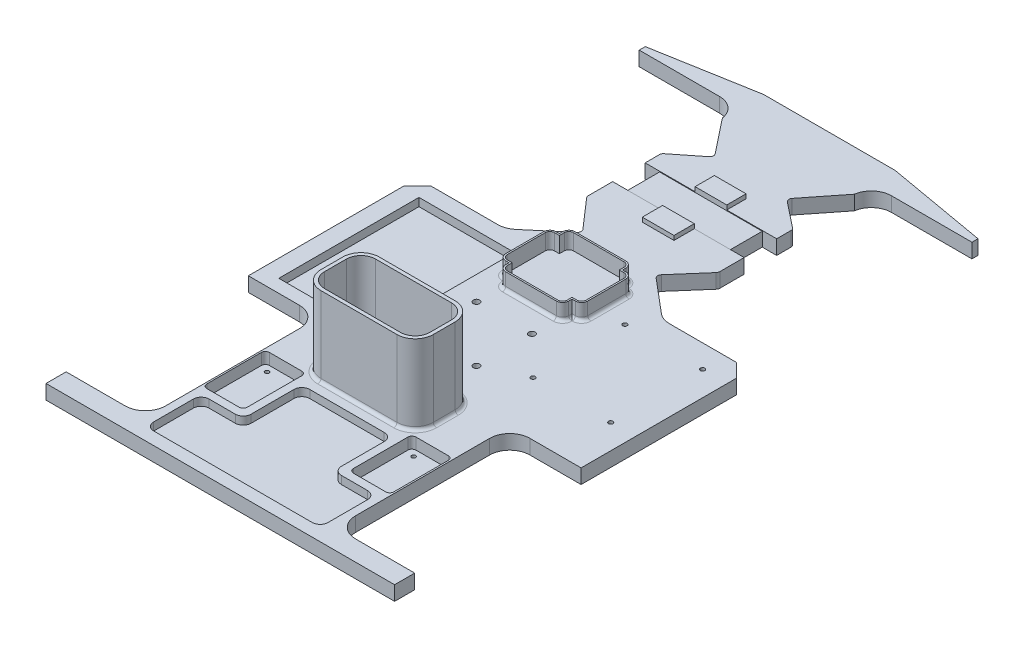
from build123d import *

# Parameters (mm, degrees)
BOSS_EXTRUDE1_DEPTH = 7.62
CUT_EXTRUDE1_DEPTH  = 401.20242682
FILLET2_R           = 12.7
FILLET3_R           = 12.7
BOSS_EXTRUDE2_DEPTH = 50
FILLET4_R           = 2
CUT_EXTRUDE3_START  = -5.08
CUT_EXTRUDE3_DEPTH  = 5.08
CUT_EXTRUDE4_DEPTH  = 7.15
SKETCH13_W          = 83
SKETCH13_H          = 20.5
CUT_EXTRUDE5_DEPTH  = 0.43499
SKETCH14_W          = 20.5
SKETCH14_H          = 7.18501
CUT_EXTRUDE6_DEPTH  = 9.1
SKETCH15_W          = 20.5
SKETCH15_H          = 7.18501
CUT_EXTRUDE7_DEPTH  = 9.1
SKETCH11_W          = 60.25
SKETCH11_H          = 88.46
CUT_EXTRUDE8_DEPTH  = 5.08
BOSS_EXTRUDE3_DEPTH = 1.5
SKETCH17_W          = 20
SKETCH17_H          = 12.188741635
SKETCH17_H_2        = 12.811258365
BOSS_EXTRUDE4_DEPTH = 2.74001
SKETCH18_R          = 2
SKETCH18_R_2        = 1.375
SKETCH18_R_3        = 1.27
SKETCH18_R_4        = 1
CUT_EXTRUDE9_DEPTH  = 404.241761271
CUT_EXTRUDE10_DEPTH = 404.241761271
CUT_EXTRUDE11_DEPTH = 5
FILLET5_R           = 2.5
BOSS_EXTRUDE5_DEPTH = 10
FILLET6_R           = 2


with BuildPart() as part:
    # Sketch4 → Boss-Extrude1 (new body)
    with BuildSketch(Plane(origin=(0, 0, 0), x_dir=(1, 0, 0), z_dir=(0, 1, 0))):
        Polygon((56.7, 201.69), (56.7, 186.69), (-6.8, 186.69), (-6.8, 80.01), (38.2, 80.01), (38.2, -29.99), (-11.8, -29.99), (-11.8, -42.69), (208.2, -42.69), (208.2, -29.99), (158.2, -29.99), (158.2, 80.01), (203.2, 80.01), (203.2, 186.69), (139.7, 186.69), (139.7, 201.69), (139.7, 236.69), (139.7, 276.69), (139.7, 326.69), (203.2, 326.69), (203.2, 330.5), (139.7, 341.696763275), (56.7, 341.696763275), (-6.8, 330.5), (-6.8, 326.69), (56.7, 326.69), (56.7, 311.69), (56.7, 236.69), align=None)
    extrude(amount=BOSS_EXTRUDE1_DEPTH)

    # Sketch5 → Cut-Extrude1 (cut, through all)
    with BuildSketch(Plane(origin=(0, 7.62, 0), x_dir=(1, 0, 0), z_dir=(0, 1, 0))):
        Polygon((-6.8, 186.69), (-6.8, 178.204718626), (1.685281374, 186.69), align=None)
        Polygon((194.714718626, 186.69), (203.2, 178.204718626), (203.2, 186.69), align=None)
    extrude(amount=-CUT_EXTRUDE1_DEPTH, mode=Mode.SUBTRACT)

    # Fillet2
    fillet2_edges = [part.edges().sort_by_distance(p)[0] for p in [
        (139.7, 3.81, -186.69),
        (139.7, 3.81, -326.69),
        (56.7, 3.81, -186.69),
        (56.7, 3.81, -326.69),
    ]]
    fillet(fillet2_edges, radius=FILLET2_R)

    # Fillet3
    fillet3_edges = [part.edges().sort_by_distance(p)[0] for p in [
        (158.2, 3.81, 29.99),
        (158.2, 3.81, -80.01),
        (38.2, 3.81, 29.99),
        (38.2, 3.81, -80.01),
    ]]
    fillet(fillet3_edges, radius=FILLET3_R)

    # Sketch6 → Boss-Extrude2 (add)
    with BuildSketch(Plane(origin=(0, 7.62, 0), x_dir=(1, 0, 0), z_dir=(0, 1, 0))):
        with BuildLine():
            Line((74.235100031, 81.57233804), (122.164900031, 81.572337374))
            ThreePointArc((122.164900031, 81.572337374), (130.296168152, 78.204255822), (133.664249871, 70.072987771))
            Line((133.664249871, 70.072987771), (133.664250347, 56.306187771))
            ThreePointArc((133.664250347, 56.306187771), (130.296168795, 48.174919093), (122.164900187, 44.806837374))
            Line((122.164900187, 44.806837374), (74.235100187, 44.80683804))
            ThreePointArc((74.235100187, 44.80683804), (66.103832067, 48.174919592), (62.735750347, 56.306187643))
            Line((62.735750347, 56.306187643), (62.735749871, 70.072987643))
            ThreePointArc((62.735749871, 70.072987643), (66.103831423, 78.20425632), (74.235100031, 81.57233804))
        make_face()
        with BuildLine():
            Line((64.985750347, 56.306187721), (64.985749871, 70.072987721))
            ThreePointArc((64.985749871, 70.072987721), (67.694821697, 76.613266079), (74.2351, 79.32233804))
            Line((74.2351, 79.32233804), (122.1649, 79.322337374))
            ThreePointArc((122.1649, 79.322337374), (128.70517791, 76.613265548), (131.414249871, 70.072987693))
            Line((131.414249871, 70.072987693), (131.414250347, 56.306187693))
            ThreePointArc((131.414250347, 56.306187693), (128.705178521, 49.765909334), (122.164900218, 47.056837374))
            Line((122.164900218, 47.056837374), (74.235100218, 47.05683804))
            ThreePointArc((74.235100218, 47.05683804), (67.694822308, 49.765909866), (64.985750347, 56.306187721))
        make_face(mode=Mode.SUBTRACT)
    extrude(amount=BOSS_EXTRUDE2_DEPTH)

    # Fillet4
    fillet4_edges = [part.edges().sort_by_distance(p)[0] for p in [
        (66.103832067, 7.62, -48.174919592),
        (98.200000187, 7.62, -44.806837707),
        (130.296168795, 7.62, -48.174919093),
        (133.664250109, 7.62, -63.189587771),
        (130.296168152, 7.62, -78.204255822),
        (98.200000031, 7.62, -81.572337707),
        (66.103831423, 7.62, -78.20425632),
        (62.735750109, 7.62, -63.189587643),
    ]]
    fillet(fillet4_edges, radius=FILLET4_R)

    # Sketch6_5 → Cut-Extrude3 (cut)
    with BuildSketch(Plane(origin=(0, 7.62, 0), x_dir=(1, 0, 0), z_dir=(0, 1, 0)).offset(CUT_EXTRUDE3_START)):
        with BuildLine():
            Line((64.985749871, 70.072987721), (64.985750347, 56.306187721))
            ThreePointArc((64.985750347, 56.306187721), (67.694822308, 49.765909866), (74.235100218, 47.05683804))
            Line((74.235100218, 47.05683804), (122.164900218, 47.056837374))
            ThreePointArc((122.164900218, 47.056837374), (128.705178521, 49.765909334), (131.414250347, 56.306187693))
            Line((131.414250347, 56.306187693), (131.414249871, 70.072987693))
            ThreePointArc((131.414249871, 70.072987693), (128.70517791, 76.613265548), (122.1649, 79.322337374))
            Line((122.1649, 79.322337374), (74.2351, 79.32233804))
            ThreePointArc((74.2351, 79.32233804), (67.694821697, 76.613266079), (64.985749871, 70.072987721))
        make_face()
    extrude(amount=CUT_EXTRUDE3_DEPTH, mode=Mode.SUBTRACT)

    # Sketch8 → Cut-Extrude4 (cut)
    with BuildSketch(Plane(origin=(0, 7.62, 0), x_dir=(1, 0, 0), z_dir=(0, 1, 0))):
        with BuildLine():
            ThreePointArc((41.74, 44.76), (39.943948776, 44.016051224), (39.2, 42.22))
            Line((39.2, 42.22), (39.2, 7.8))
            ThreePointArc((39.2, 7.8), (39.943948776, 6.003948776), (41.74, 5.26))
            Line((41.74, 5.26), (62.16, 5.26))
            ThreePointArc((62.16, 5.26), (63.956051224, 6.003948776), (64.7, 7.8))
            Line((64.7, 7.8), (64.7, 42.22))
            ThreePointArc((64.7, 42.22), (63.956051224, 44.016051224), (62.16, 44.76))
            Line((62.16, 44.76), (41.74, 44.76))
        make_face()
        with BuildLine():
            Line((154.66, 44.76), (134.24, 44.76))
            ThreePointArc((134.24, 44.76), (132.443948776, 44.016051224), (131.7, 42.22))
            Line((131.7, 42.22), (131.7, 7.8))
            ThreePointArc((131.7, 7.8), (132.443948776, 6.003948776), (134.24, 5.26))
            Line((134.24, 5.26), (154.66, 5.26))
            ThreePointArc((154.66, 5.26), (156.456051224, 6.003948776), (157.2, 7.8))
            Line((157.2, 7.8), (157.2, 42.22))
            ThreePointArc((157.2, 42.22), (156.456051224, 44.016051224), (154.66, 44.76))
        make_face()
    extrude(amount=-CUT_EXTRUDE4_DEPTH, mode=Mode.SUBTRACT)

    # Sketch13 → Cut-Extrude5 (cut)
    with BuildSketch(Plane(origin=(0, 7.62, 0), x_dir=(1, 0, 0), z_dir=(0, 1, 0))):
        with Locations((98.2, 256.69)):
            Rectangle(SKETCH13_W, SKETCH13_H)
    extrude(amount=-CUT_EXTRUDE5_DEPTH, mode=Mode.SUBTRACT)

    # Sketch14 → Cut-Extrude6 (cut)
    with BuildSketch(Plane.ZY.offset(-56.7)):
        with Locations((-256.69, 3.592505)):
            Rectangle(SKETCH14_W, SKETCH14_H)
    extrude(amount=-CUT_EXTRUDE6_DEPTH, mode=Mode.SUBTRACT)

    # Sketch15 → Cut-Extrude7 (cut)
    with BuildSketch(Plane(origin=(139.7, 0, 0), x_dir=(0, 0, -1), z_dir=(1, 0, 0))):
        with Locations((256.69, 3.592505)):
            Rectangle(SKETCH15_W, SKETCH15_H)
    extrude(amount=-CUT_EXTRUDE7_DEPTH, mode=Mode.SUBTRACT)

    # Sketch11 → Cut-Extrude8 (cut)
    with BuildSketch(Plane(origin=(0, 7.62, 0), x_dir=(1, 0, 0), z_dir=(0, 1, 0))):
        with Locations((34.325, 132.46)):
            Rectangle(SKETCH11_W, SKETCH11_H)
    extrude(amount=-CUT_EXTRUDE8_DEPTH, mode=Mode.SUBTRACT)

    # Sketch16 → Boss-Extrude3 (add)
    with BuildSketch(Plane.XZ):
        with BuildLine():
            Line((130.6, -246.44), (139.7, -246.44))
            Line((139.7, -246.44), (139.7, -199.39))
            ThreePointArc((139.7, -199.39), (143.419743879, -190.409743879), (152.4, -186.69))
            Line((152.4, -186.69), (194.714718626, -186.69))
            Line((194.714718626, -186.69), (203.2, -178.204718626))
            Line((203.2, -178.204718626), (203.2, -80.01))
            Line((203.2, -80.01), (170.9, -80.01))
            ThreePointArc((170.9, -80.01), (161.919743879, -76.290256121), (158.2, -67.31))
            Line((158.2, -67.31), (158.2, 17.29))
            ThreePointArc((158.2, 17.29), (161.919743879, 26.270256121), (170.9, 29.99))
            Line((170.9, 29.99), (208.2, 29.99))
            Line((208.2, 29.99), (208.2, 42.69))
            Line((208.2, 42.69), (-11.8, 42.69))
            Line((-11.8, 42.69), (-11.8, 29.99))
            Line((-11.8, 29.99), (25.5, 29.99))
            ThreePointArc((25.5, 29.99), (34.480256121, 26.270256121), (38.2, 17.29))
            Line((38.2, 17.29), (38.2, -67.31))
            ThreePointArc((38.2, -67.31), (34.480256121, -76.290256121), (25.5, -80.01))
            Line((25.5, -80.01), (-6.8, -80.01))
            Line((-6.8, -80.01), (-6.8, -178.204718626))
            Line((-6.8, -178.204718626), (1.685281374, -186.69))
            Line((1.685281374, -186.69), (44, -186.69))
            ThreePointArc((44, -186.69), (52.980256121, -190.409743879), (56.7, -199.39))
            Line((56.7, -199.39), (56.7, -246.44))
            Line((56.7, -246.44), (65.8, -246.44))
            Line((65.8, -246.44), (65.8, -266.94))
            Line((65.8, -266.94), (56.7, -266.94))
            Line((56.7, -266.94), (56.7, -313.99))
            ThreePointArc((56.7, -313.99), (52.980256121, -322.970256121), (44, -326.69))
            Line((44, -326.69), (-6.8, -326.69))
            Line((-6.8, -326.69), (-6.8, -330.5))
            Line((-6.8, -330.5), (56.7, -341.696763275))
            Line((56.7, -341.696763275), (139.7, -341.696763275))
            Line((139.7, -341.696763275), (203.2, -330.5))
            Line((203.2, -330.5), (203.2, -326.69))
            Line((203.2, -326.69), (152.4, -326.69))
            ThreePointArc((152.4, -326.69), (143.419743879, -322.970256121), (139.7, -313.99))
            Line((139.7, -313.99), (139.7, -266.94))
            Line((139.7, -266.94), (130.6, -266.94))
            Line((130.6, -266.94), (130.6, -246.44))
        make_face()
    extrude(amount=BOSS_EXTRUDE3_DEPTH)

    # Sketch17 → Boss-Extrude4 (add)
    with BuildSketch(Plane(origin=(0, 7.62, 0), x_dir=(1, 0, 0), z_dir=(0, 1, 0))):
        with Locations((98.2, 273.034370818)):
            Rectangle(SKETCH17_W, SKETCH17_H)
        with Locations((98.2, 240.034370818)):
            Rectangle(SKETCH17_W, SKETCH17_H_2)
    extrude(amount=BOSS_EXTRUDE4_DEPTH)

    # Sketch18 → Cut-Extrude9 (cut, through all)
    with BuildSketch(Plane(origin=(0, 7.62, 0), x_dir=(1, 0, 0), z_dir=(0, 1, 0))):
        with Locations((79.421390026, 137.748707855)):
            Circle(SKETCH18_R)
        with Locations((79.421390026, 102.748707855)):
            Circle(SKETCH18_R)
        with Locations((114.421390026, 137.748707855)):
            Circle(SKETCH18_R)
        with Locations((114.421390026, 102.748707855)):
            Circle(SKETCH18_R)
        with Locations((138.7, 114.19)):
            Circle(SKETCH18_R_2)
        with Locations((187.7, 114.19)):
            Circle(SKETCH18_R_2)
        with Locations((187.7, 172.19)):
            Circle(SKETCH18_R_2)
        with Locations((138.7, 172.19)):
            Circle(SKETCH18_R_2)
        with Locations((59.36397425, 40.497408)):
            Circle(SKETCH18_R_3)
        with Locations((44.52397425, 40.497408)):
            Circle(SKETCH18_R_3)
        with Locations((44.52397425, 9.527408)):
            Circle(SKETCH18_R_3)
        with Locations((59.36397425, 9.527408)):
            Circle(SKETCH18_R_3)
        with Locations((137.02397425, 9.527408)):
            Circle(SKETCH18_R_3)
        with Locations((151.86397425, 9.527408)):
            Circle(SKETCH18_R_3)
        with Locations((151.86397425, 40.497408)):
            Circle(SKETCH18_R_3)
        with Locations((137.02397425, 40.497408)):
            Circle(SKETCH18_R_3)
        with Locations((98.45818237, 238.878741635)):
            Circle(SKETCH18_R_4)
        with Locations((98.45818237, 273.878741635)):
            Circle(SKETCH18_R_4)
    extrude(amount=-CUT_EXTRUDE9_DEPTH, mode=Mode.SUBTRACT)

    # Sketch20 → Cut-Extrude10 (cut, through all)
    with BuildSketch(Plane(origin=(0, 7.62, 0), x_dir=(1, 0, 0), z_dir=(0, 1, 0))):
        with BuildLine():
            Line((121.29420234, 208.981872288), (139.7, 230.108326069))
            Line((139.7, 230.108326069), (139.7, 199.39))
            ThreePointArc((139.7, 199.39), (140.88511792, 194.032996109), (144.219289872, 189.675784551))
            Line((144.219289872, 189.675784551), (121.29420234, 208.981872288))
        make_face()
        Polygon((139.833467491, 315.826371611), (139.7, 313.99), (139.7, 277.167730227), (120.971300539, 291.984980177), align=None)
        Polygon((56.7, 277.167730227), (75.428699461, 291.984980177), (56.566532509, 315.826371611), (56.7, 313.99), align=None)
        with BuildLine():
            Line((75.10579766, 208.981872288), (56.7, 230.108326069))
            Line((56.7, 230.108326069), (56.7, 199.39))
            ThreePointArc((56.7, 199.39), (55.51488208, 194.032996109), (52.180710128, 189.675784551))
            Line((52.180710128, 189.675784551), (75.10579766, 208.981872288))
        make_face()
    extrude(amount=-CUT_EXTRUDE10_DEPTH, mode=Mode.SUBTRACT)

    # Sketch21 → Cut-Extrude11 (cut)
    with BuildSketch(Plane(origin=(0, 7.62, 0), x_dir=(1, 0, 0), z_dir=(0, 1, 0))):
        with BuildLine():
            Line((74.7, 37.26763454), (121.7, 37.26763454))
            ThreePointArc((121.7, 37.26763454), (125.235533906, 35.803168446), (126.7, 32.26763454))
            Line((126.7, 32.26763454), (126.7, 5.26))
            ThreePointArc((126.7, 5.26), (128.164466094, 1.724466094), (131.7, 0.26))
            Line((131.7, 0.26), (148.2, 0.26))
            ThreePointArc((148.2, 0.26), (151.735533906, -1.204466094), (153.2, -4.74))
            Line((153.2, -4.74), (153.2, -29.69))
            ThreePointArc((153.2, -29.69), (151.735533906, -33.225533906), (148.2, -34.69))
            Line((148.2, -34.69), (126.7, -34.69))
            Line((126.7, -34.69), (69.7, -34.69))
            Line((69.7, -34.69), (48.2, -34.69))
            ThreePointArc((48.2, -34.69), (44.664466094, -33.225533906), (43.2, -29.69))
            Line((43.2, -29.69), (43.2, -4.74))
            ThreePointArc((43.2, -4.74), (44.664466094, -1.204466094), (48.2, 0.26))
            Line((48.2, 0.26), (64.7, 0.26))
            ThreePointArc((64.7, 0.26), (68.235533906, 1.724466094), (69.7, 5.26))
            Line((69.7, 5.26), (69.7, 32.26763454))
            ThreePointArc((69.7, 32.26763454), (71.164466094, 35.803168446), (74.7, 37.26763454))
        make_face()
    extrude(amount=-CUT_EXTRUDE11_DEPTH, mode=Mode.SUBTRACT)

    # Fillet5
    fillet5_edges = [part.edges().sort_by_distance(p)[0] for p in [
        (139.7, 3.06, -230.108326069),
        (139.7, 3.06, -277.167730227),
        (120.971300539, 3.06, -291.984980177),
        (56.7, 3.06, -277.167730227),
        (75.428699461, 3.06, -291.984980177),
        (121.29420234, 3.06, -208.981872288),
        (56.7, 3.06, -230.108326069),
        (75.10579766, 3.06, -208.981872288),
    ]]
    fillet(fillet5_edges, radius=FILLET5_R)

    # Sketch22 → Boss-Extrude5 (add)
    with BuildSketch(Plane(origin=(0, 7.62, 0), x_dir=(1, 0, 0), z_dir=(0, 1, 0))):
        with BuildLine():
            Line((78.3, 159.403016825), (76.2, 159.403016825))
            ThreePointArc((76.2, 159.403016825), (73.442283553, 160.545300378), (72.3, 163.303016825))
            Line((72.3, 163.303016825), (72.3, 187.303016825))
            ThreePointArc((72.3, 187.303016825), (73.442283553, 190.060733272), (76.2, 191.203016825))
            Line((76.2, 191.203016825), (78.3, 191.203016825))
            Line((78.3, 191.203016825), (78.3, 193.303016825))
            ThreePointArc((78.3, 193.303016825), (79.442283553, 196.060733272), (82.2, 197.203016825))
            Line((82.2, 197.203016825), (114.2, 197.203016825))
            ThreePointArc((114.2, 197.203016825), (116.957716447, 196.060733272), (118.1, 193.303016825))
            Line((118.1, 193.303016825), (118.1, 191.203016825))
            Line((118.1, 191.203016825), (120.2, 191.203016825))
            ThreePointArc((120.2, 191.203016825), (122.957716447, 190.060733272), (124.1, 187.303016825))
            Line((124.1, 187.303016825), (124.1, 163.303016825))
            ThreePointArc((124.1, 163.303016825), (122.957716447, 160.545300378), (120.2, 159.403016825))
            Line((120.2, 159.403016825), (118.1, 159.403016825))
            Line((118.1, 159.403016825), (118.1, 157.303016825))
            ThreePointArc((118.1, 157.303016825), (116.957716447, 154.545300378), (114.2, 153.403016825))
            Line((114.2, 153.403016825), (82.2, 153.403016825))
            ThreePointArc((82.2, 153.403016825), (79.442283553, 154.545300378), (78.3, 157.303016825))
            Line((78.3, 157.303016825), (78.3, 159.403016825))
        make_face()
        with BuildLine():
            Line((79.3, 160.403016825), (76.2, 160.403016825))
            ThreePointArc((76.2, 160.403016825), (74.149390335, 161.25240716), (73.3, 163.303016825))
            Line((73.3, 163.303016825), (73.3, 187.303016825))
            ThreePointArc((73.3, 187.303016825), (74.149390335, 189.35362649), (76.2, 190.203016825))
            Line((76.2, 190.203016825), (79.3, 190.203016825))
            Line((79.3, 190.203016825), (79.3, 193.303016825))
            ThreePointArc((79.3, 193.303016825), (80.149390335, 195.35362649), (82.2, 196.203016825))
            Line((82.2, 196.203016825), (114.2, 196.203016825))
            ThreePointArc((114.2, 196.203016825), (116.250609665, 195.35362649), (117.1, 193.303016825))
            Line((117.1, 193.303016825), (117.1, 190.203016825))
            Line((117.1, 190.203016825), (120.2, 190.203016825))
            ThreePointArc((120.2, 190.203016825), (122.250609665, 189.35362649), (123.1, 187.303016825))
            Line((123.1, 187.303016825), (123.1, 163.303016825))
            ThreePointArc((123.1, 163.303016825), (122.250609665, 161.25240716), (120.2, 160.403016825))
            Line((120.2, 160.403016825), (117.1, 160.403016825))
            Line((117.1, 160.403016825), (117.1, 157.303016825))
            ThreePointArc((117.1, 157.303016825), (116.250609665, 155.25240716), (114.2, 154.403016825))
            Line((114.2, 154.403016825), (82.2, 154.403016825))
            ThreePointArc((82.2, 154.403016825), (80.149390335, 155.25240716), (79.3, 157.303016825))
            Line((79.3, 157.303016825), (79.3, 160.403016825))
        make_face(mode=Mode.SUBTRACT)
    extrude(amount=BOSS_EXTRUDE5_DEPTH)

    # Fillet6
    fillet6_edges = [part.edges().sort_by_distance(p)[0] for p in [
        (119.15, 7.62, -159.403016825),
        (122.957716447, 7.62, -160.545300378),
        (119.15, 7.62, -191.203016825),
        (122.957716447, 7.62, -190.060733272),
        (118.1, 7.62, -192.253016825),
        (116.957716447, 7.62, -196.060733272),
        (78.3, 7.62, -192.253016825),
        (79.442283553, 7.62, -196.060733272),
        (78.3, 7.62, -158.353016825),
        (118.1, 7.62, -158.353016825),
        (116.957716447, 7.62, -154.545300378),
        (98.2, 7.62, -153.403016825),
        (77.25, 7.62, -191.203016825),
        (73.442283553, 7.62, -190.060733272),
        (77.25, 7.62, -159.403016825),
        (73.442283553, 7.62, -160.545300378),
        (124.1, 7.62, -175.303016825),
        (98.2, 7.62, -197.203016825),
        (79.442283553, 7.62, -154.545300378),
        (72.3, 7.62, -175.303016825),
    ]]
    fillet(fillet6_edges, radius=FILLET6_R)


solid = part.part
